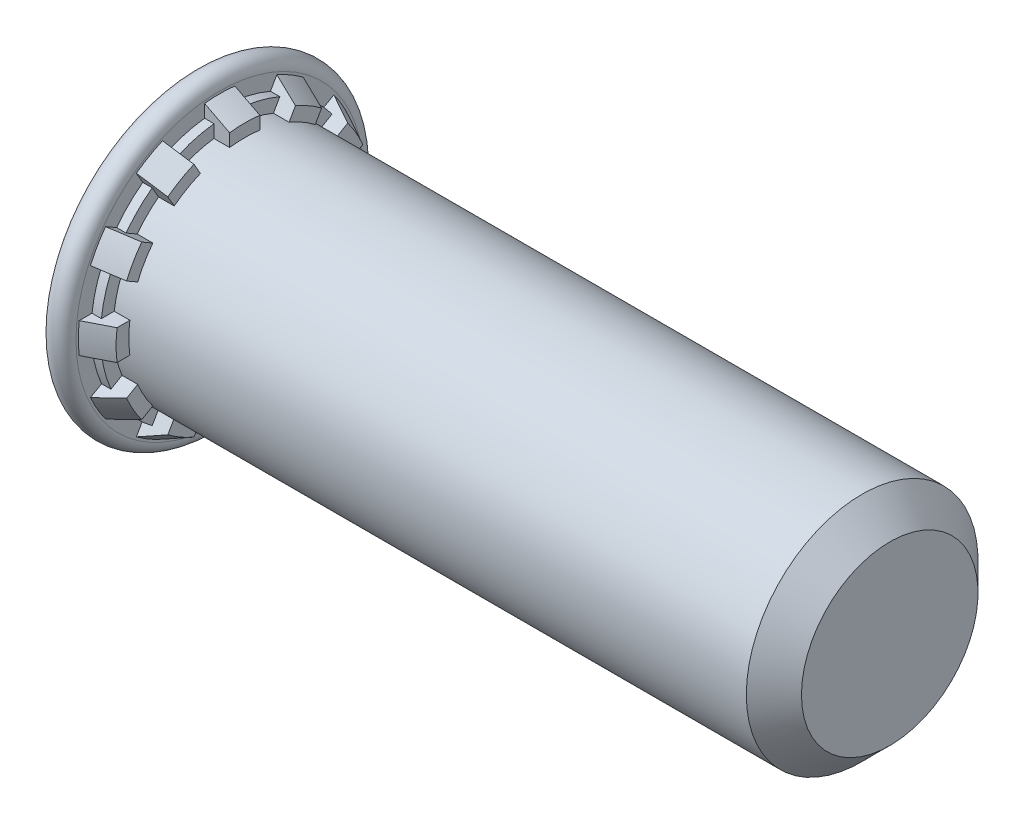
from build123d import *

# Parameters (mm, degrees)
RIBCUT1_DEPTH    = 0.428625
RIBCUT2_DEPTH    = 0.6858
RIBCUTSPAT_COUNT = 12
RIBCUTSPAT_ANGLE = 330


with BuildPart() as part:
    # BodySke → BaseBody (revolve)
    with BuildSketch(Plane.XY):
        with BuildLine():
            Line((0, 0), (0, 3.93446))
            Line((0, 3.93446), (0.00508, 3.93446))
            Line((0.00508, 3.93446), (0.00508, 3.93954))
            ThreePointArc((0.00508, 3.93954), (0.34544, 4.2799), (0.6858, 3.93954))
            Line((0.6858, 3.93954), (0.6858, 3.8735))
            Line((0.6858, 3.8735), (1.3716, 3.52425))
            Line((1.3716, 3.52425), (1.3716, 3.175))
            Line((1.3716, 3.175), (18.29435, 3.175))
            Line((18.29435, 3.175), (19.05, 2.41935))
            Line((19.05, 2.41935), (19.05, 0))
            Line((19.05, 0), (0, 0))
        make_face()
    revolve(axis=Axis((0, 0, 0), (1, 0, 0)))

    # RibCut1Ske → RibCut1 (cut)
    with BuildSketch(Plane(origin=(1.3716, 0, 0), x_dir=(0, 0, -1), z_dir=(1, 0, 0))):
        with BuildLine():
            Line((0.41442066, 3.147837435), (0.41442066, 4.259788672))
            ThreePointArc((0.41442066, 4.259788672), (1.107719631, 4.134065944), (1.770995516, 3.896295534))
            Line((1.770995516, 3.896295534), (1.215019898, 2.933317516))
            ThreePointArc((1.215019898, 2.933317516), (0.821750468, 3.066814498), (0.41442066, 3.147837435))
        make_face()
    ribcut1 = extrude(amount=-RIBCUT1_DEPTH, mode=Mode.SUBTRACT)

    # RibCut2Ske → RibCut2 (cut)
    with BuildSketch(Plane(origin=(1.3716, 0, 0), x_dir=(0, 0, -1), z_dir=(1, 0, 0))):
        with BuildLine():
            Line((0.41442066, 3.499799077), (0.41442066, 4.259788672))
            ThreePointArc((0.41442066, 4.259788672), (1.107719631, 4.134065944), (1.770995516, 3.896295534))
            Line((1.770995516, 3.896295534), (1.391000719, 3.238125239))
            ThreePointArc((1.391000719, 3.238125239), (0.91214302, 3.404164093), (0.41442066, 3.499799077))
        make_face()
    ribcut2 = extrude(amount=-RIBCUT2_DEPTH, mode=Mode.SUBTRACT)

    # RibCutsPat: RibCut1, RibCut2 ×12 about axis
    ribcutspat_axis = Axis((0, 0, 0), (1, 0, 0))
    for i in range(1, RIBCUTSPAT_COUNT):
        add(ribcut1.rotate(ribcutspat_axis, i * RIBCUTSPAT_ANGLE / (RIBCUTSPAT_COUNT - 1)), mode=Mode.SUBTRACT)
        add(ribcut2.rotate(ribcutspat_axis, i * RIBCUTSPAT_ANGLE / (RIBCUTSPAT_COUNT - 1)), mode=Mode.SUBTRACT)


solid = part.part
